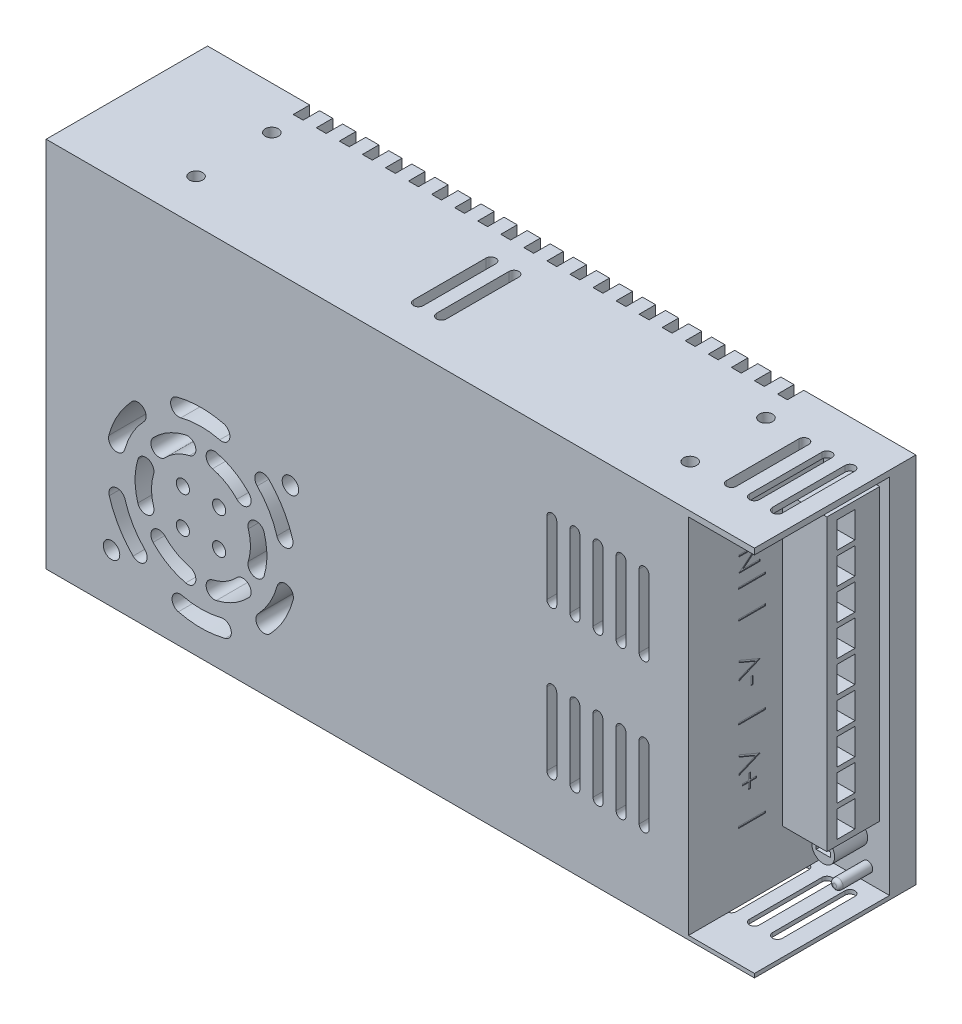
from build123d import *

# Parameters (mm, degrees)
SKETCH1_W       = 215
SKETCH1_H       = 113
EXTRUDE1_DEPTH  = 49
SKETCH2_W       = 20
SKETCH2_H       = 110
EXTRUDE2_DEPTH  = 41
SKETCH3_R       = 2.5
SKETCH3_R_2     = 2
EXTRUDE3_DEPTH  = 30
EXTRUDE4_DEPTH  = 5
SKETCH5_R       = 2
EXTRUDE5_DEPTH  = 5
SKETCH6_W       = 13.488328062
SKETCH6_H       = 88
EXTRUDE6_DEPTH  = 16
SKETCH7_R       = 3.455901714
SKETCH7_R_2     = 1.55919841
EXTRUDE7_DEPTH  = 10
FILLET1_R       = 1
SKETCH8_W       = 4.295356202
SKETCH8_H       = 1.441082083
EXTRUDE8_DEPTH  = 5
SKETCH9_W       = 5.5
SKETCH9_H       = 8
EXTRUDE9_DEPTH  = 15
SKETCH10_W      = 8.222435897
SKETCH10_H      = 0.569871795
SKETCH10_W_2    = 0.651282051
SKETCH10_H_2    = 2.442307692
SKETCH10_H_3    = 0.569871794
EXTRUDE10_DEPTH = 0.2
SKETCH11_R      = 2
EXTRUDE11_DEPTH = 3
EXTRUDE12_DEPTH = 3
EXTRUDE13_DEPTH = 3
EXTRUDE14_DEPTH = 3


with BuildPart() as part:
    # Sketch1 → Extrude1 (new body)
    with BuildSketch(Plane.XY):
        Rectangle(SKETCH1_W, SKETCH1_H)
    extrude(amount=EXTRUDE1_DEPTH)

    # Sketch2 → Extrude2 (cut)
    with BuildSketch(Plane.XY.offset(49)):
        with Locations((97.5, -0.3)):
            Rectangle(SKETCH2_W, SKETCH2_H)
    extrude(amount=-EXTRUDE2_DEPTH, mode=Mode.SUBTRACT)

    # Sketch3 → Extrude3 (cut)
    with BuildSketch(Plane.XY.offset(49)):
        with BuildLine():
            ThreePointArc((-43.152732758, -36.085304315), (-39.614571973, -31.323658323), (-37.352447543, -25.839622642))
            ThreePointArc((-37.352447543, -25.839622642), (-34.280866803, -24.088796619), (-32.530040781, -27.160377358))
            ThreePointArc((-32.530040781, -27.160377358), (-35.263441134, -33.786920473), (-39.538718749, -39.540576047))
            ThreePointArc((-39.538718749, -39.540576047), (-43.073361619, -39.619947186), (-43.152732758, -36.085304315))
        make_face()
        with BuildLine():
            ThreePointArc((-57.024176089, -34.091732184), (-53, -32.490381057), (-49.601101199, -29.806017899))
            ThreePointArc((-49.601101199, -29.806017899), (-46.066948416, -29.707204415), (-45.968134932, -33.241357198))
            ThreePointArc((-45.968134932, -33.241357198), (-50.5, -36.820508076), (-55.865568118, -38.955642912))
            ThreePointArc((-55.865568118, -38.955642912), (-58.876827467, -37.102991534), (-57.024176089, -34.091732184))
        make_face()
        with BuildLine():
            ThreePointArc((-66.189661245, -42.815826276), (-69.211066195, -44.651885133), (-67.375007338, -47.673290083))
            ThreePointArc((-67.375007338, -47.673290083), (-60.254556639, -48.498961319), (-53.149101785, -47.552883906))
            ThreePointArc((-53.149101785, -47.552883906), (-51.364447847, -44.500833723), (-54.416498029, -42.716179784))
            ThreePointArc((-54.416498029, -42.716179784), (-60.29687446, -43.499140402), (-66.189661245, -42.815826276))
        make_face()
        with BuildLine():
            ThreePointArc((-71.398898801, -29.806017899), (-74.933051584, -29.707204415), (-75.031865068, -33.241357198))
            ThreePointArc((-75.031865068, -33.241357198), (-70.5, -36.820508076), (-65.134431882, -38.955642912))
            ThreePointArc((-65.134431882, -38.955642912), (-62.123172533, -37.102991534), (-63.975823911, -34.091732184))
            ThreePointArc((-63.975823911, -34.091732184), (-68, -32.490381057), (-71.398898801, -29.806017899))
        make_face()
        with BuildLine():
            ThreePointArc((-83.536928488, -26.230521961), (-81.182302487, -31.675482079), (-77.564050487, -36.376557143))
            ThreePointArc((-77.564050487, -36.376557143), (-77.583581043, -39.912037104), (-81.119061005, -39.892506547))
            ThreePointArc((-81.119061005, -39.892506547), (-85.491115505, -34.212040845), (-88.336288589, -27.632714036))
            ThreePointArc((-88.336288589, -27.632714036), (-86.637704576, -24.531937947), (-83.536928488, -26.230521961))
        make_face()
        with Locations((-87.652487563, -41.584891195)):
            Circle(SKETCH3_R)
        with BuildLine():
            ThreePointArc((-77.847267242, -2.914695685), (-77.926638381, 0.619947186), (-81.461281251, 0.540576047))
            ThreePointArc((-81.461281251, 0.540576047), (-85.736558866, -5.213079527), (-88.469959219, -11.839622642))
            ThreePointArc((-88.469959219, -11.839622642), (-86.719133197, -14.911203381), (-83.647552457, -13.160377358))
            ThreePointArc((-83.647552457, -13.160377358), (-81.385428027, -7.676341677), (-77.847267242, -2.914695685))
        make_face()
        with BuildLine():
            ThreePointArc((-79.66629695, -13.785714286), (-80.5, -19.5), (-79.66629695, -25.214285714))
            ThreePointArc((-79.66629695, -25.214285714), (-76.556224117, -26.895787119), (-74.874722712, -23.785714286))
            ThreePointArc((-74.874722712, -23.785714286), (-75.5, -19.5), (-74.874722712, -15.214285714))
            ThreePointArc((-74.874722712, -15.214285714), (-76.556224117, -12.104212881), (-79.66629695, -13.785714286))
        make_face()
        with Locations((-55, -25)):
            Circle(SKETCH3_R_2)
        with Locations((-66, -25)):
            Circle(SKETCH3_R_2)
        with Locations((-66, -14)):
            Circle(SKETCH3_R_2)
        with Locations((-55, -14)):
            Circle(SKETCH3_R_2)
        with BuildLine():
            ThreePointArc((-49.601101199, -9.193982101), (-53, -6.509618943), (-57.024176089, -4.908267816))
            ThreePointArc((-57.024176089, -4.908267816), (-58.876827467, -1.897008466), (-55.865568118, -0.044357088))
            ThreePointArc((-55.865568118, -0.044357088), (-50.5, -2.179491924), (-45.968134932, -5.758642802))
            ThreePointArc((-45.968134932, -5.758642802), (-46.066948416, -9.292795585), (-49.601101199, -9.193982101))
        make_face()
        with BuildLine():
            ThreePointArc((-63.975823911, -4.908267816), (-68, -6.509618943), (-71.398898801, -9.193982101))
            ThreePointArc((-71.398898801, -9.193982101), (-74.933051584, -9.292795585), (-75.031865068, -5.758642802))
            ThreePointArc((-75.031865068, -5.758642802), (-70.5, -2.179491924), (-65.134431882, -0.044357088))
            ThreePointArc((-65.134431882, -0.044357088), (-62.123172533, -1.897008466), (-63.975823911, -4.908267816))
        make_face()
        with BuildLine():
            ThreePointArc((-54.810338755, 3.815826276), (-60.70312554, 4.499140402), (-66.583501971, 3.716179784))
            ThreePointArc((-66.583501971, 3.716179784), (-69.635552153, 5.500833723), (-67.850898215, 8.552883906))
            ThreePointArc((-67.850898215, 8.552883906), (-60.745443361, 9.498961319), (-53.624992662, 8.673290083))
            ThreePointArc((-53.624992662, 8.673290083), (-51.788933805, 5.651885133), (-54.810338755, 3.815826276))
        make_face()
        with BuildLine():
            ThreePointArc((-37.463071512, -12.769478039), (-39.817697513, -7.324517921), (-43.435949513, -2.623442857))
            ThreePointArc((-43.435949513, -2.623442857), (-43.416418957, 0.912037104), (-39.880938995, 0.892506547))
            ThreePointArc((-39.880938995, 0.892506547), (-35.508884495, -4.787959155), (-32.663711411, -11.367285964))
            ThreePointArc((-32.663711411, -11.367285964), (-34.362295424, -14.468062053), (-37.463071512, -12.769478039))
        make_face()
        with BuildLine():
            ThreePointArc((-46.125277288, -23.785714286), (-44.443775883, -26.895787119), (-41.33370305, -25.214285714))
            ThreePointArc((-41.33370305, -25.214285714), (-40.5, -19.5), (-41.33370305, -13.785714286))
            ThreePointArc((-41.33370305, -13.785714286), (-44.443775883, -12.104212881), (-46.125277288, -15.214285714))
            ThreePointArc((-46.125277288, -15.214285714), (-45.5, -19.5), (-46.125277288, -23.785714286))
        make_face()
        with Locations((-33.347512437, 2.584891195)):
            Circle(SKETCH3_R)
        with BuildLine():
            ThreePointArc((54.5, -33.5), (53, -35), (51.5, -33.5))
            Line((51.5, -33.5), (51.5, -11.5))
            ThreePointArc((51.5, -11.5), (53, -10), (54.5, -11.5))
            Line((54.5, -11.5), (54.5, -33.5))
        make_face()
        with BuildLine():
            ThreePointArc((54.5, 11.5), (53, 10), (51.5, 11.5))
            Line((51.5, 11.5), (51.5, 33.5))
            ThreePointArc((51.5, 33.5), (53, 35), (54.5, 33.5))
            Line((54.5, 33.5), (54.5, 11.5))
        make_face()
        with BuildLine():
            Line((47.5, -11.5), (47.5, -33.5))
            ThreePointArc((47.5, -33.5), (46, -35), (44.5, -33.5))
            Line((44.5, -33.5), (44.5, -11.5))
            ThreePointArc((44.5, -11.5), (46, -10), (47.5, -11.5))
        make_face()
        with BuildLine():
            Line((61.5, -11.5), (61.5, -33.5))
            ThreePointArc((61.5, -33.5), (60, -35), (58.5, -33.5))
            Line((58.5, -33.5), (58.5, -11.5))
            ThreePointArc((58.5, -11.5), (60, -10), (61.5, -11.5))
        make_face()
        with BuildLine():
            Line((65.5, -11.5), (65.5, -33.5))
            ThreePointArc((65.5, -33.5), (67, -35), (68.5, -33.5))
            Line((68.5, -33.5), (68.5, -11.5))
            ThreePointArc((68.5, -11.5), (67, -10), (65.5, -11.5))
        make_face()
        with BuildLine():
            Line((75.5, -11.5), (75.5, -33.5))
            ThreePointArc((75.5, -33.5), (74, -35), (72.5, -33.5))
            Line((72.5, -33.5), (72.5, -11.5))
            ThreePointArc((72.5, -11.5), (74, -10), (75.5, -11.5))
        make_face()
        with BuildLine():
            Line((75.5, 33.5), (75.5, 11.5))
            ThreePointArc((75.5, 11.5), (74, 10), (72.5, 11.5))
            Line((72.5, 11.5), (72.5, 33.5))
            ThreePointArc((72.5, 33.5), (74, 35), (75.5, 33.5))
        make_face()
        with BuildLine():
            Line((68.5, 33.5), (68.5, 11.5))
            ThreePointArc((68.5, 11.5), (67, 10), (65.5, 11.5))
            Line((65.5, 11.5), (65.5, 33.5))
            ThreePointArc((65.5, 33.5), (67, 35), (68.5, 33.5))
        make_face()
        with BuildLine():
            Line((61.5, 33.5), (61.5, 11.5))
            ThreePointArc((61.5, 11.5), (60, 10), (58.5, 11.5))
            Line((58.5, 11.5), (58.5, 33.5))
            ThreePointArc((58.5, 33.5), (60, 35), (61.5, 33.5))
        make_face()
        with BuildLine():
            Line((44.5, 33.5), (44.5, 11.5))
            ThreePointArc((44.5, 11.5), (46, 10), (47.5, 11.5))
            Line((47.5, 11.5), (47.5, 33.5))
            ThreePointArc((47.5, 33.5), (46, 35), (44.5, 33.5))
        make_face()
    extrude(amount=-EXTRUDE3_DEPTH, mode=Mode.SUBTRACT)

    # Sketch4 → Extrude4 (cut)
    with BuildSketch(Plane(origin=(0, 0, 0), x_dir=(-1, 0, 0), z_dir=(0, 0, -1))):
        with BuildLine():
            Line((-73.5, 56.5), (-70.5, 56.5))
            Line((-70.5, 56.5), (-70.5, 36))
            ThreePointArc((-70.5, 36), (-72, 34.5), (-73.5, 36))
            Line((-73.5, 36), (-73.5, 56.5))
        make_face()
        with BuildLine():
            Line((-63.5, 56.5), (-63.5, 36))
            ThreePointArc((-63.5, 36), (-65, 34.5), (-66.5, 36))
            Line((-66.5, 36), (-66.5, 56.5))
            Line((-66.5, 56.5), (-63.5, 56.5))
        make_face()
        with BuildLine():
            Line((-56.5, 56.5), (-56.5, 36))
            ThreePointArc((-56.5, 36), (-58, 34.5), (-59.5, 36))
            Line((-59.5, 36), (-59.5, 56.5))
            Line((-59.5, 56.5), (-56.5, 56.5))
        make_face()
        with BuildLine():
            Line((-49.5, 56.5), (-49.5, 36))
            ThreePointArc((-49.5, 36), (-51, 34.5), (-52.5, 36))
            Line((-52.5, 36), (-52.5, 56.5))
            Line((-52.5, 56.5), (-49.5, 56.5))
        make_face()
        with BuildLine():
            Line((-42.5, 56.5), (-42.5, 36))
            ThreePointArc((-42.5, 36), (-44, 34.5), (-45.5, 36))
            Line((-45.5, 36), (-45.5, 56.5))
            Line((-45.5, 56.5), (-42.5, 56.5))
        make_face()
        with BuildLine():
            Line((-35.5, 56.5), (-35.5, 36))
            ThreePointArc((-35.5, 36), (-37, 34.5), (-38.5, 36))
            Line((-38.5, 36), (-38.5, 56.5))
            Line((-38.5, 56.5), (-35.5, 56.5))
        make_face()
        with BuildLine():
            Line((-28.5, 56.5), (-28.5, 36))
            ThreePointArc((-28.5, 36), (-30, 34.5), (-31.5, 36))
            Line((-31.5, 36), (-31.5, 56.5))
            Line((-31.5, 56.5), (-28.5, 56.5))
        make_face()
        with BuildLine():
            Line((-21.5, 56.5), (-21.5, 36))
            ThreePointArc((-21.5, 36), (-23, 34.5), (-24.5, 36))
            Line((-24.5, 36), (-24.5, 56.5))
            Line((-24.5, 56.5), (-21.5, 56.5))
        make_face()
        with BuildLine():
            Line((-14.5, 56.5), (-14.5, 36))
            ThreePointArc((-14.5, 36), (-16, 34.5), (-17.5, 36))
            Line((-17.5, 36), (-17.5, 56.5))
            Line((-17.5, 56.5), (-14.5, 56.5))
        make_face()
        with BuildLine():
            Line((-7.5, 56.5), (-7.5, 36))
            ThreePointArc((-7.5, 36), (-9, 34.5), (-10.5, 36))
            Line((-10.5, 36), (-10.5, 56.5))
            Line((-10.5, 56.5), (-7.5, 56.5))
        make_face()
        with BuildLine():
            Line((-0.5, 56.5), (-0.5, 36))
            ThreePointArc((-0.5, 36), (-2, 34.5), (-3.5, 36))
            Line((-3.5, 36), (-3.5, 56.5))
            Line((-3.5, 56.5), (-0.5, 56.5))
        make_face()
        with BuildLine():
            Line((6.5, 56.5), (6.5, 36))
            ThreePointArc((6.5, 36), (5, 34.5), (3.5, 36))
            Line((3.5, 36), (3.5, 56.5))
            Line((3.5, 56.5), (6.5, 56.5))
        make_face()
        with BuildLine():
            Line((13.5, 56.5), (13.5, 36))
            ThreePointArc((13.5, 36), (12, 34.5), (10.5, 36))
            Line((10.5, 36), (10.5, 56.5))
            Line((10.5, 56.5), (13.5, 56.5))
        make_face()
        with BuildLine():
            Line((20.5, 56.5), (20.5, 36))
            ThreePointArc((20.5, 36), (19, 34.5), (17.5, 36))
            Line((17.5, 36), (17.5, 56.5))
            Line((17.5, 56.5), (20.5, 56.5))
        make_face()
        with BuildLine():
            Line((27.5, 56.5), (27.5, 36))
            ThreePointArc((27.5, 36), (26, 34.5), (24.5, 36))
            Line((24.5, 36), (24.5, 56.5))
            Line((24.5, 56.5), (27.5, 56.5))
        make_face()
        with BuildLine():
            Line((34.5, 56.5), (34.5, 36))
            ThreePointArc((34.5, 36), (33, 34.5), (31.5, 36))
            Line((31.5, 36), (31.5, 56.5))
            Line((31.5, 56.5), (34.5, 56.5))
        make_face()
        with BuildLine():
            Line((41.5, 56.5), (41.5, 36))
            ThreePointArc((41.5, 36), (40, 34.5), (38.5, 36))
            Line((38.5, 36), (38.5, 56.5))
            Line((38.5, 56.5), (41.5, 56.5))
        make_face()
        with BuildLine():
            Line((48.5, 56.5), (48.5, 36))
            ThreePointArc((48.5, 36), (47, 34.5), (45.5, 36))
            Line((45.5, 36), (45.5, 56.5))
            Line((45.5, 56.5), (48.5, 56.5))
        make_face()
        with BuildLine():
            Line((55.5, 56.5), (55.5, 36))
            ThreePointArc((55.5, 36), (54, 34.5), (52.5, 36))
            Line((52.5, 36), (52.5, 56.5))
            Line((52.5, 56.5), (55.5, 56.5))
        make_face()
        with BuildLine():
            Line((62.5, 56.5), (62.5, 36))
            ThreePointArc((62.5, 36), (61, 34.5), (59.5, 36))
            Line((59.5, 36), (59.5, 56.5))
            Line((59.5, 56.5), (62.5, 56.5))
        make_face()
        with BuildLine():
            Line((69.5, 56.5), (69.5, 36))
            ThreePointArc((69.5, 36), (68, 34.5), (66.5, 36))
            Line((66.5, 36), (66.5, 56.5))
            Line((66.5, 56.5), (69.5, 56.5))
        make_face()
        with BuildLine():
            Line((76.5, 56.5), (76.5, 36))
            ThreePointArc((76.5, 36), (75, 34.5), (73.5, 36))
            Line((73.5, 36), (73.5, 56.5))
            Line((73.5, 56.5), (76.5, 56.5))
        make_face()
        with BuildLine():
            Line((73.5, -56.5), (73.5, -36))
            ThreePointArc((73.5, -36), (75, -34.5), (76.5, -36))
            Line((76.5, -36), (76.5, -56.5))
            Line((76.5, -56.5), (73.5, -56.5))
        make_face()
        with BuildLine():
            Line((66.5, -56.5), (66.5, -36))
            ThreePointArc((66.5, -36), (68, -34.5), (69.5, -36))
            Line((69.5, -36), (69.5, -56.5))
            Line((69.5, -56.5), (66.5, -56.5))
        make_face()
        with BuildLine():
            Line((59.5, -56.5), (59.5, -36))
            ThreePointArc((59.5, -36), (61, -34.5), (62.5, -36))
            Line((62.5, -36), (62.5, -56.5))
            Line((62.5, -56.5), (59.5, -56.5))
        make_face()
        with BuildLine():
            Line((52.5, -56.5), (52.5, -36))
            ThreePointArc((52.5, -36), (54, -34.5), (55.5, -36))
            Line((55.5, -36), (55.5, -56.5))
            Line((55.5, -56.5), (52.5, -56.5))
        make_face()
        with BuildLine():
            Line((45.5, -56.5), (45.5, -36))
            ThreePointArc((45.5, -36), (47, -34.5), (48.5, -36))
            Line((48.5, -36), (48.5, -56.5))
            Line((48.5, -56.5), (45.5, -56.5))
        make_face()
        with BuildLine():
            Line((38.5, -56.5), (38.5, -36))
            ThreePointArc((38.5, -36), (40, -34.5), (41.5, -36))
            Line((41.5, -36), (41.5, -56.5))
            Line((41.5, -56.5), (38.5, -56.5))
        make_face()
        with BuildLine():
            Line((31.5, -56.5), (31.5, -36))
            ThreePointArc((31.5, -36), (33, -34.5), (34.5, -36))
            Line((34.5, -36), (34.5, -56.5))
            Line((34.5, -56.5), (31.5, -56.5))
        make_face()
        with BuildLine():
            Line((24.5, -56.5), (24.5, -36))
            ThreePointArc((24.5, -36), (26, -34.5), (27.5, -36))
            Line((27.5, -36), (27.5, -56.5))
            Line((27.5, -56.5), (24.5, -56.5))
        make_face()
        with BuildLine():
            Line((17.5, -56.5), (17.5, -36))
            ThreePointArc((17.5, -36), (19, -34.5), (20.5, -36))
            Line((20.5, -36), (20.5, -56.5))
            Line((20.5, -56.5), (17.5, -56.5))
        make_face()
        with BuildLine():
            Line((10.5, -56.5), (10.5, -36))
            ThreePointArc((10.5, -36), (12, -34.5), (13.5, -36))
            Line((13.5, -36), (13.5, -56.5))
            Line((13.5, -56.5), (10.5, -56.5))
        make_face()
        with BuildLine():
            Line((3.5, -56.5), (3.5, -36))
            ThreePointArc((3.5, -36), (5, -34.5), (6.5, -36))
            Line((6.5, -36), (6.5, -56.5))
            Line((6.5, -56.5), (3.5, -56.5))
        make_face()
        with BuildLine():
            Line((-3.5, -56.5), (-3.5, -36))
            ThreePointArc((-3.5, -36), (-2, -34.5), (-0.5, -36))
            Line((-0.5, -36), (-0.5, -56.5))
            Line((-0.5, -56.5), (-3.5, -56.5))
        make_face()
        with BuildLine():
            Line((-10.5, -56.5), (-10.5, -36))
            ThreePointArc((-10.5, -36), (-9, -34.5), (-7.5, -36))
            Line((-7.5, -36), (-7.5, -56.5))
            Line((-7.5, -56.5), (-10.5, -56.5))
        make_face()
        with BuildLine():
            Line((-17.5, -56.5), (-17.5, -36))
            ThreePointArc((-17.5, -36), (-16, -34.5), (-14.5, -36))
            Line((-14.5, -36), (-14.5, -56.5))
            Line((-14.5, -56.5), (-17.5, -56.5))
        make_face()
        with BuildLine():
            Line((-24.5, -56.5), (-24.5, -36))
            ThreePointArc((-24.5, -36), (-23, -34.5), (-21.5, -36))
            Line((-21.5, -36), (-21.5, -56.5))
            Line((-21.5, -56.5), (-24.5, -56.5))
        make_face()
        with BuildLine():
            Line((-31.5, -56.5), (-31.5, -36))
            ThreePointArc((-31.5, -36), (-30, -34.5), (-28.5, -36))
            Line((-28.5, -36), (-28.5, -56.5))
            Line((-28.5, -56.5), (-31.5, -56.5))
        make_face()
        with BuildLine():
            Line((-38.5, -56.5), (-38.5, -36))
            ThreePointArc((-38.5, -36), (-37, -34.5), (-35.5, -36))
            Line((-35.5, -36), (-35.5, -56.5))
            Line((-35.5, -56.5), (-38.5, -56.5))
        make_face()
        with BuildLine():
            Line((-45.5, -56.5), (-45.5, -36))
            ThreePointArc((-45.5, -36), (-44, -34.5), (-42.5, -36))
            Line((-42.5, -36), (-42.5, -56.5))
            Line((-42.5, -56.5), (-45.5, -56.5))
        make_face()
        with BuildLine():
            Line((-52.5, -56.5), (-52.5, -36))
            ThreePointArc((-52.5, -36), (-51, -34.5), (-49.5, -36))
            Line((-49.5, -36), (-49.5, -56.5))
            Line((-49.5, -56.5), (-52.5, -56.5))
        make_face()
        with BuildLine():
            Line((-59.5, -56.5), (-59.5, -36))
            ThreePointArc((-59.5, -36), (-58, -34.5), (-56.5, -36))
            Line((-56.5, -36), (-56.5, -56.5))
            Line((-56.5, -56.5), (-59.5, -56.5))
        make_face()
        with BuildLine():
            Line((-66.5, -56.5), (-66.5, -36))
            ThreePointArc((-66.5, -36), (-65, -34.5), (-63.5, -36))
            Line((-63.5, -36), (-63.5, -56.5))
            Line((-63.5, -56.5), (-66.5, -56.5))
        make_face()
        with BuildLine():
            Line((-70.5, -56.5), (-70.5, -36))
            ThreePointArc((-70.5, -36), (-72, -34.5), (-73.5, -36))
            Line((-73.5, -36), (-73.5, -56.5))
            Line((-73.5, -56.5), (-70.5, -56.5))
        make_face()
    extrude(amount=-EXTRUDE4_DEPTH, mode=Mode.SUBTRACT)

    # Sketch5 → Extrude5 (cut)
    with BuildSketch(Plane(origin=(0, 0, 0), x_dir=(-1, 0, 0), z_dir=(0, 0, -1))):
        with Locations((-75, 25)):
            Circle(SKETCH5_R)
        with Locations((-75, -25)):
            Circle(SKETCH5_R)
        with Locations((75, 25)):
            Circle(SKETCH5_R)
        with Locations((75, -25)):
            Circle(SKETCH5_R)
    extrude(amount=-EXTRUDE5_DEPTH, mode=Mode.SUBTRACT)

    # Sketch6 → Extrude6 (add)
    with BuildSketch(Plane.XY.offset(8)):
        with Locations((97.755835969, 6.7)):
            Rectangle(SKETCH6_W, SKETCH6_H)
    extrude(amount=EXTRUDE6_DEPTH)

    # Sketch7 → Extrude7 (add)
    with BuildSketch(Plane.XY.offset(8)):
        with Locations((97.393666593, -43.531856833)):
            Circle(SKETCH7_R)
        with Locations((100.849568308, -50.994767489)):
            Circle(SKETCH7_R_2)
    extrude(amount=EXTRUDE7_DEPTH)

    # Fillet1
    fillet1_edges = [part.edges().sort_by_distance(p)[0] for p in [
        (99.290369898, -50.994767489, 18),
    ]]
    fillet(fillet1_edges, radius=FILLET1_R)

    # Sketch8 → Extrude8 (cut)
    with BuildSketch(Plane.XY.offset(18)):
        with Locations((97.376021487, -43.601720802)):
            Rectangle(SKETCH8_W, SKETCH8_H)
    extrude(amount=-EXTRUDE8_DEPTH, mode=Mode.SUBTRACT)

    # Sketch9 → Extrude9 (cut)
    with BuildSketch(Plane(origin=(104.5, 0, 0), x_dir=(0, 0, -1), z_dir=(1, 0, 0))):
        with Locations((-18.25, -31.6)):
            Rectangle(SKETCH9_W, SKETCH9_H)
        with Locations((-18.25, -22.1)):
            Rectangle(SKETCH9_W, SKETCH9_H)
        with Locations((-18.25, -12.6)):
            Rectangle(SKETCH9_W, SKETCH9_H)
        with Locations((-18.25, -3.1)):
            Rectangle(SKETCH9_W, SKETCH9_H)
        with Locations((-18.25, 6.4)):
            Rectangle(SKETCH9_W, SKETCH9_H)
        with Locations((-18.25, 15.9)):
            Rectangle(SKETCH9_W, SKETCH9_H)
        with Locations((-18.25, 25.4)):
            Rectangle(SKETCH9_W, SKETCH9_H)
        with Locations((-18.25, 34.9)):
            Rectangle(SKETCH9_W, SKETCH9_H)
        with Locations((-18.25, 44.4)):
            Rectangle(SKETCH9_W, SKETCH9_H)
    extrude(amount=-EXTRUDE9_DEPTH, mode=Mode.SUBTRACT)

    # Sketch10 → Extrude10 (cut)
    with BuildSketch(Plane(origin=(87.5, 0, 0), x_dir=(0, 0, -1), z_dir=(1, 0, 0))):
        with Locations((-29.727011069, -34.501768975)):
            Rectangle(SKETCH10_W, SKETCH10_H)
        Polygon((-30.744639273, -24.203371539), (-32.617075171, -24.203371539), (-32.617075171, -23.633499744), (-30.744639273, -23.633499744), (-30.744639273, -21.761063847), (-30.174767479, -21.761063847), (-30.174767479, -23.633499744), (-28.302331581, -23.633499744), (-28.302331581, -24.203371539), (-30.174767479, -24.203371539), (-30.174767479, -26.075807436), (-30.744639273, -26.075807436), align=None)
        Polygon((-33.675408504, -20.946961282), (-33.675408504, -20.336384359), (-28.671221805, -18.219717693), (-33.675408504, -16.103051026), (-33.675408504, -15.492474103), (-27.325408504, -18.179012564), (-27.325408504, -18.260422821), align=None)
        with Locations((-29.727011069, -7.310743333)):
            Rectangle(SKETCH10_W, SKETCH10_H)
        with Locations((-29.767716197, 2.092141282)):
            Rectangle(SKETCH10_W_2, SKETCH10_H_2)
        Polygon((-33.675408504, 3.883166923), (-33.675408504, 4.493743846), (-28.671221805, 6.610410512), (-33.675408504, 8.727077179), (-33.675408504, 9.337654102), (-27.325408504, 6.651115641), (-27.325408504, 6.569705384), align=None)
        with Locations((-29.727011069, 19.961692564)):
            Rectangle(SKETCH10_W, SKETCH10_H)
        with Locations((-29.727011069, 28.346948974)):
            Rectangle(SKETCH10_W, SKETCH10_H_3)
        Polygon((-27.325408504, 32.213936153), (-33.675408504, 32.213936153), (-33.675408504, 32.333507468), (-28.677581982, 36.528679743), (-33.675408504, 36.528679743), (-33.675408504, 37.098551538), (-27.325408504, 37.098551538), (-27.325408504, 36.968803942), (-32.311786709, 32.783807948), (-27.325408504, 32.783807948), align=None)
        with Locations((-29.727011069, 40.802718205)):
            Rectangle(SKETCH10_W, SKETCH10_H)
        Polygon((-33.675408504, 44.669705384), (-33.675408504, 45.239577179), (-27.976690555, 45.239577179), (-27.976690555, 47.681884871), (-27.325408504, 47.681884871), (-27.325408504, 44.669705384), align=None)
        with Locations((-29.727011069, 50.816179744)):
            Rectangle(SKETCH10_W, SKETCH10_H)
    extrude(amount=-EXTRUDE10_DEPTH, mode=Mode.SUBTRACT)

    # Sketch11 → Extrude11 (cut)
    with BuildSketch(Plane(origin=(0, 56.5, 0), x_dir=(1, 0, 0), z_dir=(0, 1, 0))):
        with Locations((-75, -13)):
            Circle(SKETCH11_R)
        with Locations((-75, -36)):
            Circle(SKETCH11_R)
        with Locations((75, -13)):
            Circle(SKETCH11_R)
        with Locations((75, -36)):
            Circle(SKETCH11_R)
    extrude(amount=-EXTRUDE11_DEPTH, mode=Mode.SUBTRACT)

    # Sketch12 → Extrude12 (cut)
    with BuildSketch(Plane(origin=(0, 56.5, 0), x_dir=(1, 0, 0), z_dir=(0, 1, 0))):
        with BuildLine():
            Line((99.5, -13.5), (99.5, -35.5))
            ThreePointArc((99.5, -35.5), (101, -37), (102.5, -35.5))
            Line((102.5, -35.5), (102.5, -13.5))
            ThreePointArc((102.5, -13.5), (101, -12), (99.5, -13.5))
        make_face()
        with BuildLine():
            Line((95.5, -13.5), (95.5, -35.5))
            ThreePointArc((95.5, -35.5), (94, -37), (92.5, -35.5))
            Line((92.5, -35.5), (92.5, -13.5))
            ThreePointArc((92.5, -13.5), (94, -12), (95.5, -13.5))
        make_face()
        with BuildLine():
            Line((88.5, -13.5), (88.5, -35.5))
            ThreePointArc((88.5, -35.5), (87, -37), (85.5, -35.5))
            Line((85.5, -35.5), (85.5, -13.5))
            ThreePointArc((85.5, -13.5), (87, -12), (88.5, -13.5))
        make_face()
    extrude(amount=-EXTRUDE12_DEPTH, mode=Mode.SUBTRACT)

    # Sketch13 → Extrude13 (cut)
    with BuildSketch(Plane(origin=(0, -55.3, 0), x_dir=(1, 0, 0), z_dir=(0, 1, 0))):
        with BuildLine():
            Line((95.5, -35.5), (95.5, -13.5))
            ThreePointArc((95.5, -13.5), (94, -12), (92.5, -13.5))
            Line((92.5, -13.5), (92.5, -35.5))
            ThreePointArc((92.5, -35.5), (94, -37), (95.5, -35.5))
        make_face()
        with BuildLine():
            Line((88.5, -35.5), (88.5, -13.5))
            ThreePointArc((88.5, -13.5), (87, -12), (85.5, -13.5))
            Line((85.5, -13.5), (85.5, -35.5))
            ThreePointArc((85.5, -35.5), (87, -37), (88.5, -35.5))
        make_face()
        with BuildLine():
            Line((102.5, -35.5), (102.5, -13.5))
            ThreePointArc((102.5, -13.5), (101, -12), (99.5, -13.5))
            Line((99.5, -13.5), (99.5, -35.5))
            ThreePointArc((99.5, -35.5), (101, -37), (102.5, -35.5))
        make_face()
    extrude(amount=-EXTRUDE13_DEPTH, mode=Mode.SUBTRACT)

    # Sketch14 → Extrude14 (cut)
    with BuildSketch(Plane(origin=(0, 56.5, 0), x_dir=(1, 0, 0), z_dir=(0, 1, 0))):
        with BuildLine():
            Line((0.5, -35.5), (0.5, -13.5))
            ThreePointArc((0.5, -13.5), (-1, -12), (-2.5, -13.5))
            Line((-2.5, -13.5), (-2.5, -35.5))
            ThreePointArc((-2.5, -35.5), (-1, -37), (0.5, -35.5))
        make_face()
        with BuildLine():
            Line((-6.5, -35.5), (-6.5, -13.5))
            ThreePointArc((-6.5, -13.5), (-8, -12), (-9.5, -13.5))
            Line((-9.5, -13.5), (-9.5, -35.5))
            ThreePointArc((-9.5, -35.5), (-8, -37), (-6.5, -35.5))
        make_face()
    extrude(amount=-EXTRUDE14_DEPTH, mode=Mode.SUBTRACT)


solid = part.part
